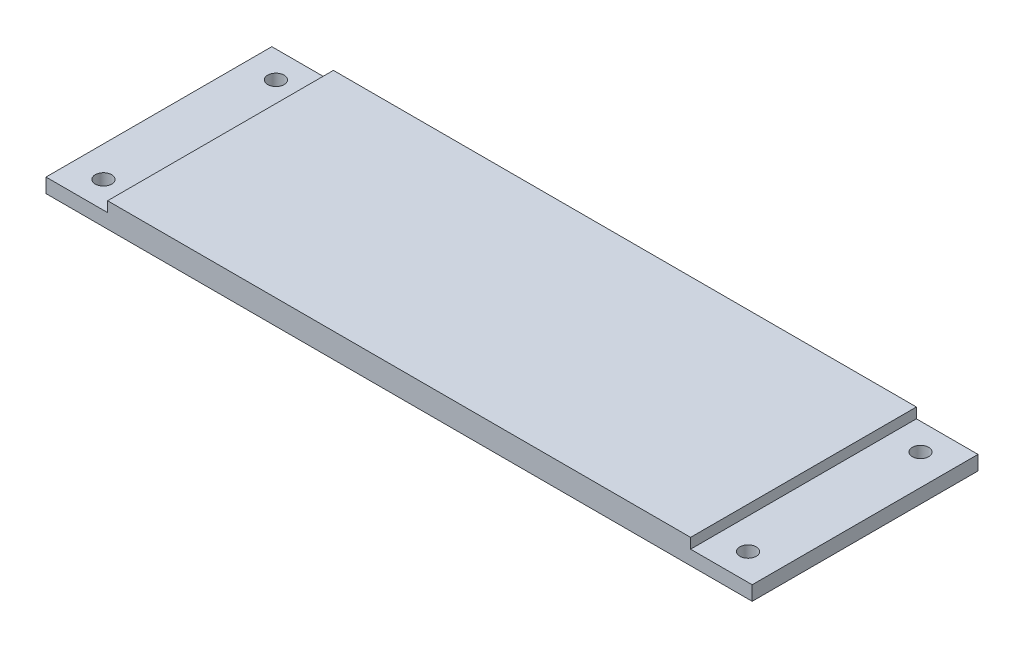
from build123d import *

# Parameters (mm, degrees)
ESQUISSE1_W             = 172
ESQUISSE1_H             = 55
BOSS_EXTRU_1_DEPTH      = 3.5
ESQUISSE2_R             = 2
ENL_V_MAT_EXTRU_1_DEPTH = 6
ESQUISSE3_W             = 142
ESQUISSE3_H             = 55
BOSS_EXTRU_2_DEPTH      = 2.5


with BuildPart() as part:
    # Esquisse1 → Boss.-Extru.1 (new body)
    with BuildSketch(Plane(origin=(0, 0, 0), x_dir=(1, 0, 0), z_dir=(0, 1, 0))):
        Rectangle(ESQUISSE1_W, ESQUISSE1_H)
    extrude(amount=BOSS_EXTRU_1_DEPTH)

    # Esquisse2 → Enlèv. mat.-Extru.1 (cut)
    with BuildSketch(Plane(origin=(0, 3.5, 0), x_dir=(1, 0, 0), z_dir=(0, 1, 0))):
        with Locations((-78.5, 21)):
            Circle(ESQUISSE2_R)
        with Locations((-78.5, -21)):
            Circle(ESQUISSE2_R)
        with Locations((78.5, -21)):
            Circle(ESQUISSE2_R)
        with Locations((78.5, 21)):
            Circle(ESQUISSE2_R)
    extrude(amount=-ENL_V_MAT_EXTRU_1_DEPTH, mode=Mode.SUBTRACT)

    # Esquisse3 → Boss.-Extru.2 (add)
    with BuildSketch(Plane(origin=(0, 3.5, 0), x_dir=(1, 0, 0), z_dir=(0, 1, 0))):
        Rectangle(ESQUISSE3_W, ESQUISSE3_H)
    extrude(amount=BOSS_EXTRU_2_DEPTH)


solid = part.part
